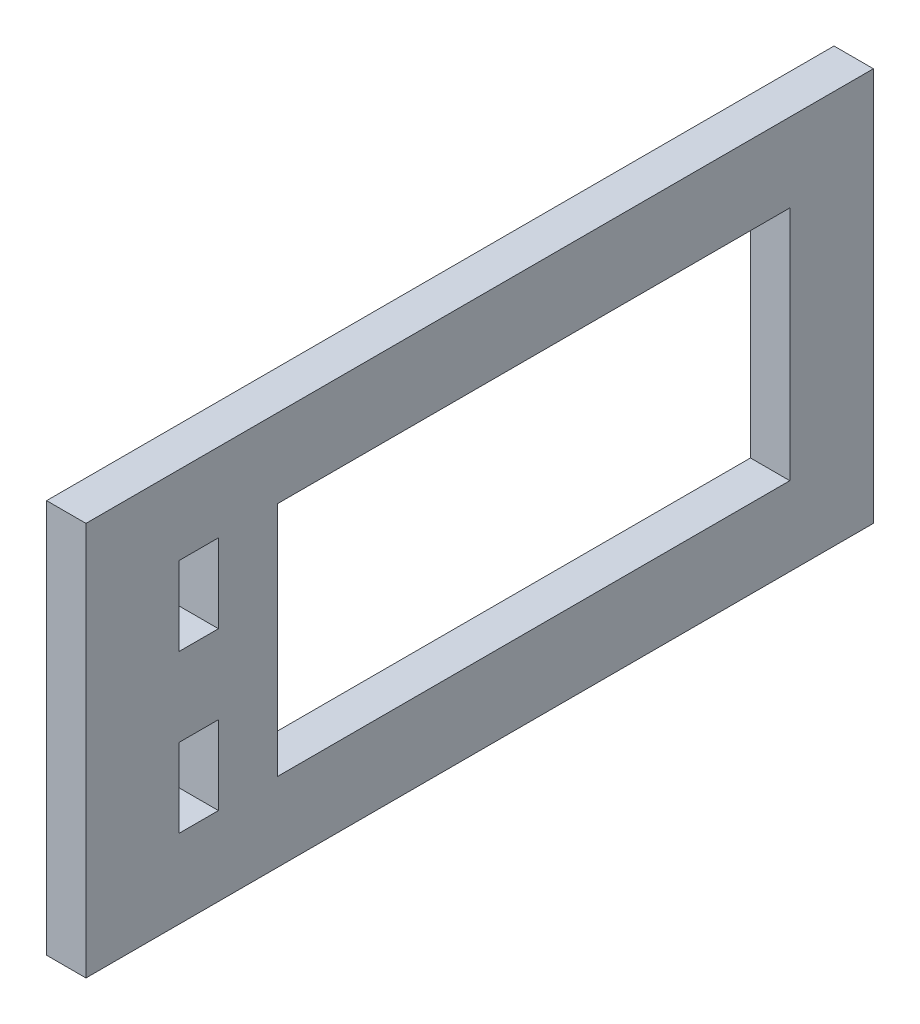
from build123d import *

# Parameters (mm, degrees)
SKETCH1_W           = 100
SKETCH1_H           = 50
SKETCH1_W_2         = 5
SKETCH1_H_2         = 10
SKETCH1_W_3         = 65.036281339
SKETCH1_H_3         = 30
BOSS_EXTRUDE3_DEPTH = 5


with BuildPart() as part:
    # Sketch1 → Boss-Extrude3 (new body)
    with BuildSketch(Plane(origin=(0, 0, 0), x_dir=(0, 0, -1), z_dir=(1, 0, 0))):
        with Locations((-50, 25)):
            Rectangle(SKETCH1_W, SKETCH1_H)
        with Locations((-85.674008316, 35)):
            Rectangle(SKETCH1_W_2, SKETCH1_H_2, mode=Mode.SUBTRACT)
        with Locations((-85.674008316, 15)):
            Rectangle(SKETCH1_W_2, SKETCH1_H_2, mode=Mode.SUBTRACT)
        with Locations((-43.133585004, 25)):
            Rectangle(SKETCH1_W_3, SKETCH1_H_3, mode=Mode.SUBTRACT)
    extrude(amount=BOSS_EXTRUDE3_DEPTH)


solid = part.part
